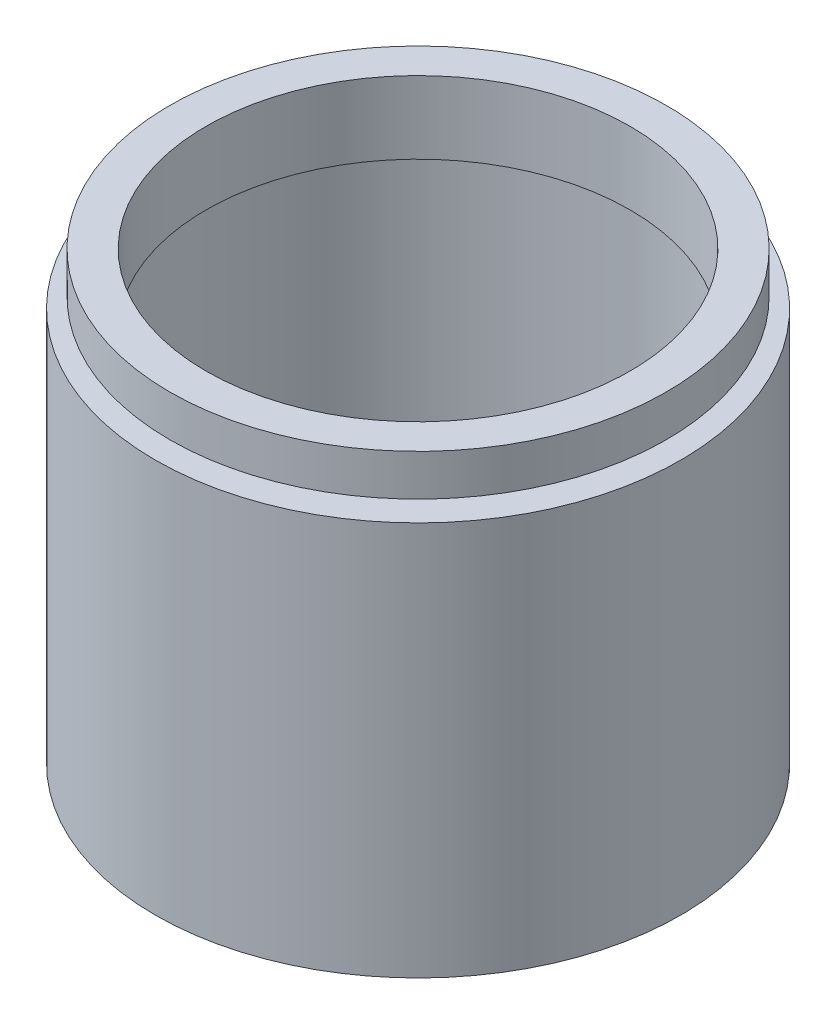
from build123d import *


with BuildPart() as part:
    # 草图1 → 旋转1 (revolve)
    with BuildSketch(Plane.XY, mode=Mode.PRIVATE) as revolve_1_sk:
        Polygon((22.5, 35.1), (24, 35.1), (24, 36.1), (20.5, 36.1), (20.5, 43.1), (24, 43.1), (24, 39.1), (22.5, 39.1), (22.5, 38.1), (23.5, 38.1), (25.4, 38.1), (25.4, 0), (22.5, 0), (22.5, 5.5), (23.5, 5.5), (23.5, 6.5), (22.5, 6.5), align=None)
    revolve(revolve_1_sk.sketch.rotate(Axis((0, 161.376166943, 0), (0, -1, 0)), 90), axis=Axis((0, 161.376166943, 0), (0, -1, 0)))  # turned: the seam where the file's is


solid = part.part
